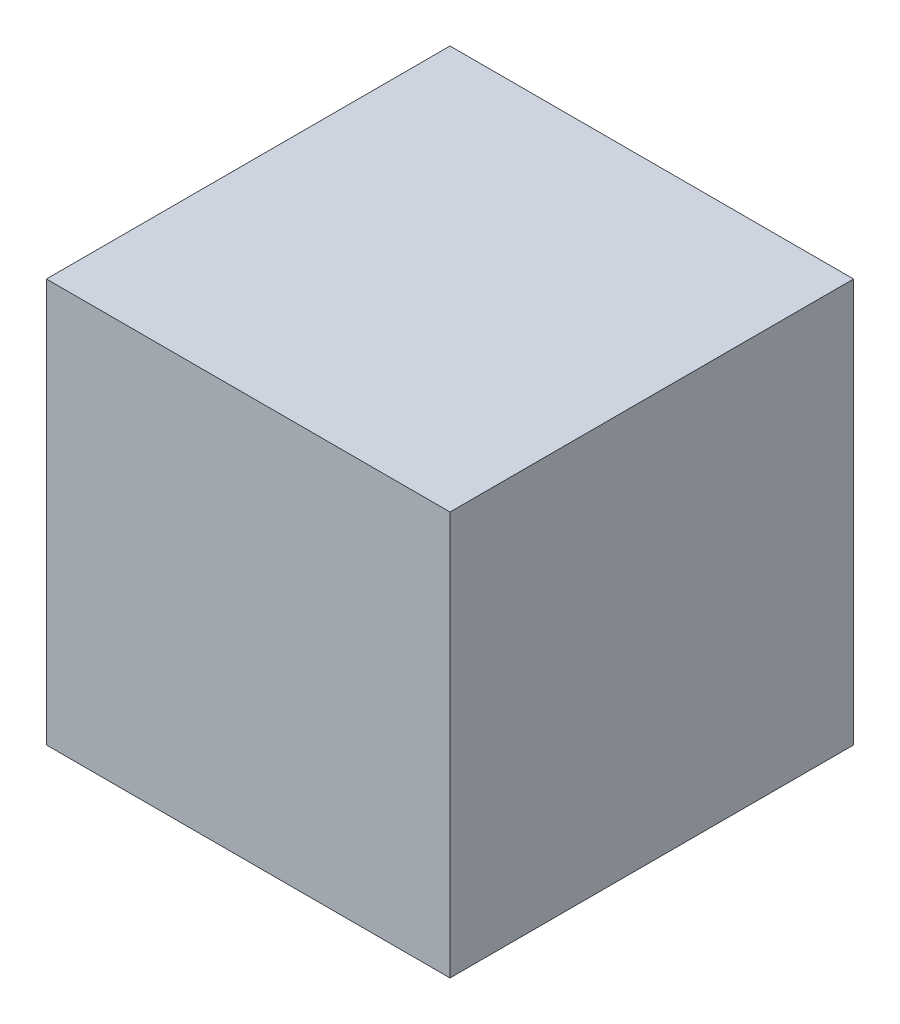
from build123d import *

# Parameters (mm, degrees)
SKETCH1_W           = 56.5
SKETCH1_H           = 56.5
BOSS_EXTRUDE1_DEPTH = 28.25


with BuildPart() as part:
    # Sketch1 → Boss-Extrude1 (new body, symmetric)
    with BuildSketch(Plane(origin=(0, 0, 0), x_dir=(1, 0, 0), z_dir=(0, 1, 0))):
        Rectangle(SKETCH1_W, SKETCH1_H)
    extrude(amount=BOSS_EXTRUDE1_DEPTH, both=True)


solid = part.part
